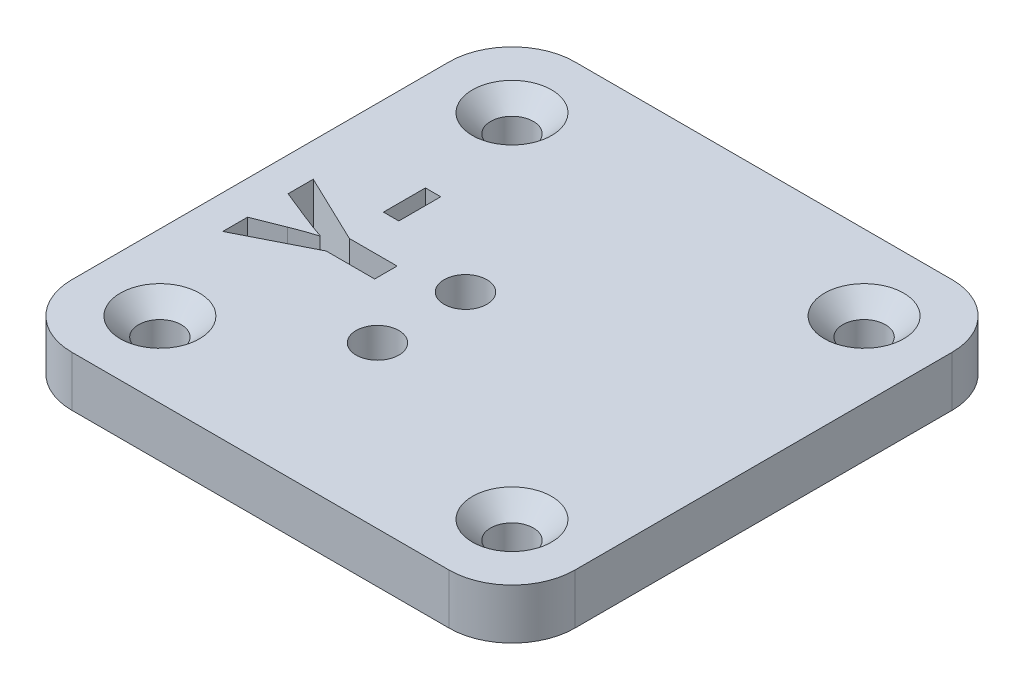
from build123d import *

# Parameters (mm, degrees)
BOSS_EXTRUDE1_DEPTH                                 = 4
CSK_FOR_M3_COUNTERSUNK_FLAT_HEAD_SCREW1_D           = 3.4
CSK_FOR_M3_COUNTERSUNK_FLAT_HEAD_SCREW1_CSINK_D     = 6.3
CSK_FOR_M3_COUNTERSUNK_FLAT_HEAD_SCREW1_CSINK_ANGLE = 90
CSK_FOR_M3_COUNTERSUNK_FLAT_HEAD_SCREW2_D           = 3.4
CSK_FOR_M3_COUNTERSUNK_FLAT_HEAD_SCREW2_CSINK_D     = 6.3
CSK_FOR_M3_COUNTERSUNK_FLAT_HEAD_SCREW2_CSINK_ANGLE = 90
SKETCH7_W                                           = 1.222113554
SKETCH7_H                                           = 3.336226563
CUT_EXTRUDE1_DEPTH                                  = 4


with BuildPart() as part:
    # Sketch1 → Boss-Extrude1 (new body)
    with BuildSketch(Plane(origin=(0, 0, 0), x_dir=(1, 0, 0), z_dir=(0, 1, 0))):
        with BuildLine():
            Line((-15, -20), (15, -20))
            ThreePointArc((15, -20), (18.535533906, -18.535533906), (20, -15))
            Line((20, -15), (20, 15))
            ThreePointArc((20, 15), (18.535533906, 18.535533906), (15, 20))
            Line((15, 20), (-15, 20))
            ThreePointArc((-15, 20), (-18.535533906, 18.535533906), (-20, 15))
            Line((-20, 15), (-20, -15))
            ThreePointArc((-20, -15), (-18.535533906, -18.535533906), (-15, -20))
        make_face()
    extrude(amount=BOSS_EXTRUDE1_DEPTH)

    # CSK for M3 Countersunk Flat Head Screw1 (through all)
    with Locations(Plane(origin=(-14, 4, -14), x_dir=(0, 0, 1), z_dir=(0, 1, 0))):
        with Locations((0, 0), (0, 28), (28, 28), (28, 0)):
            CounterSinkHole(CSK_FOR_M3_COUNTERSUNK_FLAT_HEAD_SCREW1_D / 2, CSK_FOR_M3_COUNTERSUNK_FLAT_HEAD_SCREW1_CSINK_D / 2, counter_sink_angle=CSK_FOR_M3_COUNTERSUNK_FLAT_HEAD_SCREW1_CSINK_ANGLE)

    # CSK for M3 Countersunk Flat Head Screw2 (through all)
    with Locations(Plane(origin=(0, 0, 0), x_dir=(-1, 0, 0), z_dir=(0, -1, 0))):
        with Locations((3.5, -0.1976847), (3.5, -7.1976847)):
            CounterSinkHole(CSK_FOR_M3_COUNTERSUNK_FLAT_HEAD_SCREW2_D / 2, CSK_FOR_M3_COUNTERSUNK_FLAT_HEAD_SCREW2_CSINK_D / 2, counter_sink_angle=CSK_FOR_M3_COUNTERSUNK_FLAT_HEAD_SCREW2_CSINK_ANGLE)

    # Sketch7 → Cut-Extrude1 (cut)
    with BuildSketch(Plane(origin=(0, 4, 0), x_dir=(1, 0, 0), z_dir=(0, 1, 0))):
        with Locations((-11.652287397, 3.708478162)):
            Rectangle(SKETCH7_W, SKETCH7_H)
        with BuildLine():
            add(Edge.make_bspline(
                [(-15.043692162, -2.806314504), (-14.880436161, -2.741055239), (-14.5584639, -2.612351406), (-14.077627456, -2.435113354), (-13.607003536, -2.275557203), (-13.296000815, -2.177928582), (-13.143053989, -2.129916179)],
                knots=[0, 0, 0, 0, 0.000527431, 0.001040195, 0.001537166, 0.002018074, 0.002018074, 0.002018074, 0.002018074], degree=3))
            Line((-13.143053989, -2.129916179), (-13.142217189, -2.10714082))
            add(Edge.make_bspline(
                [(-13.142217189, -2.10714082), (-13.300142366, -2.053259121), (-13.613682824, -1.946283823), (-14.081290903, -1.775427697), (-14.553659216, -1.59628161), (-14.870442844, -1.470693808), (-15.032410797, -1.406482159)],
                knots=[0, 0, 0, 0, 0.000500579, 0.000993836, 0.001493443, 0.002016132, 0.002016132, 0.002016132, 0.002016132], degree=3))
            Line((-15.032410797, -1.406482159), (-17.320356965, -0.487540494))
            Line((-17.320356965, -0.487540494), (-17.320356965, 1.515068939))
            Line((-17.320356965, 1.515068939), (-11.797862272, -1.130802918))
            Line((-11.797862272, -1.130802918), (-8.007023631, -1.130802918))
            Line((-8.007023631, -1.130802918), (-8.007023631, -2.914806972))
            Line((-8.007023631, -2.914806972), (-11.858418799, -2.914806972))
            Line((-11.858418799, -2.914806972), (-17.320356965, -5.682049098))
            Line((-17.320356965, -5.682049098), (-17.320356965, -3.703713718))
            Line((-17.320356965, -3.703713718), (-15.043692162, -2.806314504))
        make_face()
    extrude(amount=-CUT_EXTRUDE1_DEPTH, mode=Mode.SUBTRACT)


solid = part.part
